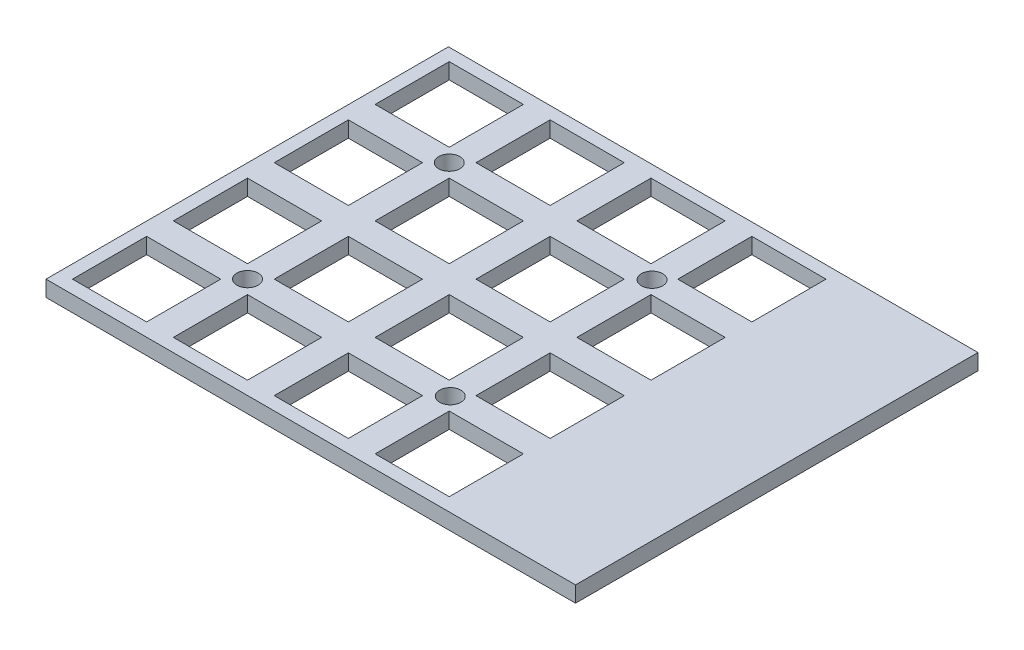
from build123d import *

# Parameters (mm, degrees)
SKETCH1_W               = 100
SKETCH1_H               = 76
BOSS_EXTRUDE1_DEPTH     = 3
CUT_EXTRUDE1_START      = -4
SKETCH2_W               = 14
SKETCH2_H               = 14
CUT_EXTRUDE1_DEPTH      = 5
LPATTERN1_COUNT         = 4
LPATTERN1_PITCH         = 19.05
LPATTERN1_COUNT_DIR2    = 4
LPATTERN1_PITCH_DIR2    = 19.05
SKETCH4_R               = 2
CUT_EXTRUDE2_DEPTH      = 1
CUT_EXTRUDE2_DEPTH_BACK = 4


with BuildPart() as part:
    # Sketch1 → Boss-Extrude1 (new body)
    with BuildSketch(Plane(origin=(0, 0, 0), x_dir=(1, 0, 0), z_dir=(0, 1, 0))):
        with Locations((50, 38)):
            Rectangle(SKETCH1_W, SKETCH1_H)
    extrude(amount=BOSS_EXTRUDE1_DEPTH)

    # Sketch2 → Cut-Extrude1 (cut)
    with BuildSketch(Plane(origin=(0, 3, 0), x_dir=(1, 0, 0), z_dir=(0, 1, 0)).offset(CUT_EXTRUDE1_START)):
        with Locations((9.5, 9.5)):
            Rectangle(SKETCH2_W, SKETCH2_H)
    cut_extrude1 = extrude(amount=CUT_EXTRUDE1_DEPTH, mode=Mode.SUBTRACT)

    # LPattern1: Cut-Extrude1 4 × 4
    with Locations(*[(j * LPATTERN1_PITCH_DIR2, 0, -i * LPATTERN1_PITCH) for i in range(LPATTERN1_COUNT) for j in range(LPATTERN1_COUNT_DIR2) if (i, j) != (0, 0)]):
        add(cut_extrude1, mode=Mode.SUBTRACT)

    # Sketch4 → Cut-Extrude2 (cut, two sides)
    with BuildSketch(Plane(origin=(0, 3, 0), x_dir=(1, 0, 0), z_dir=(0, 1, 0))) as cut_extrude2_sk:
        with Locations((19.025, 57.125)):
            Circle(SKETCH4_R)
        with Locations((57.317897374, 57.125)):
            Circle(SKETCH4_R)
        with Locations((19.025, 19.025)):
            Circle(SKETCH4_R)
        with Locations((57.317897374, 19.025)):
            Circle(SKETCH4_R)
    extrude(amount=CUT_EXTRUDE2_DEPTH, mode=Mode.SUBTRACT)
    extrude(cut_extrude2_sk.sketch, amount=-CUT_EXTRUDE2_DEPTH_BACK, mode=Mode.SUBTRACT)


solid = part.part
